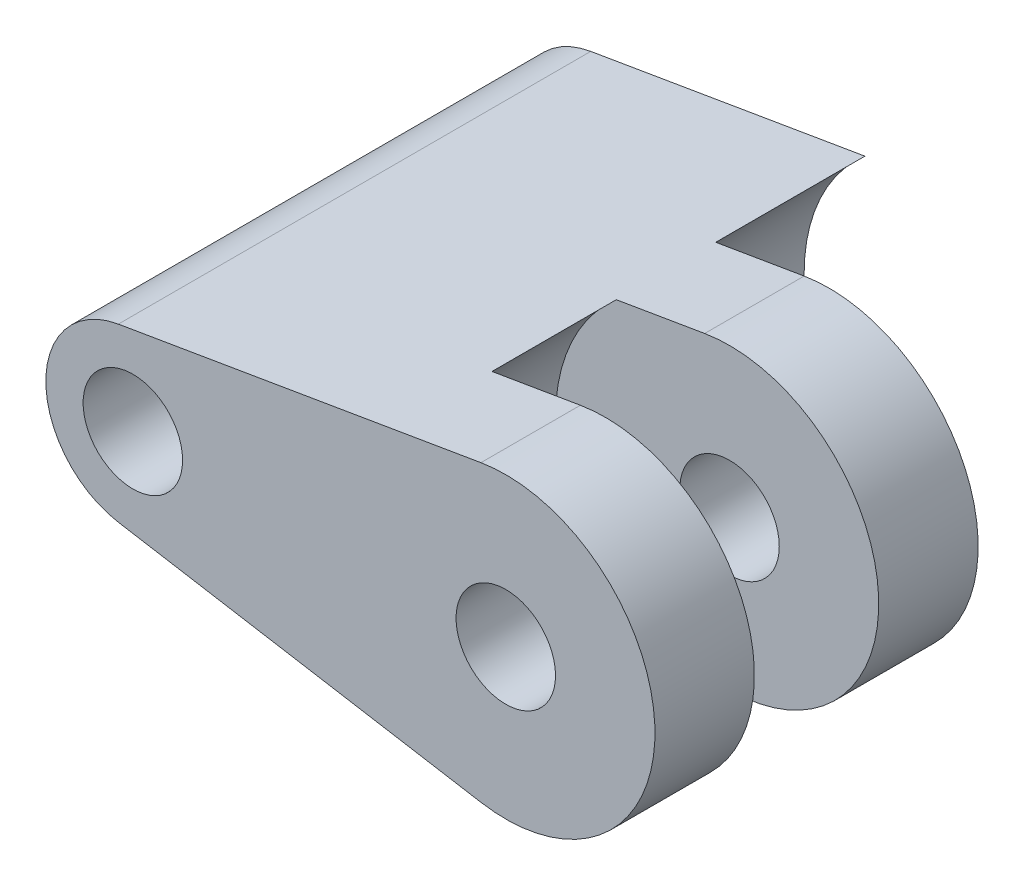
from build123d import *

# Parameters (mm, degrees)
ESQUISSE1_R        = 2
BOSS_EXTRU_2_DEPTH = 19
BOSS_EXTRU_3_START = 6
ESQUISSE1_4_R      = 2
BOSS_EXTRU_3_DEPTH = 4
BOSS_EXTRU_4_START = 15
ESQUISSE1_5_R      = 2
BOSS_EXTRU_4_DEPTH = 4


with BuildPart() as part:
    # Esquisse1 → Boss.-Extru.2 (new body)
    with BuildSketch(Plane.XY):
        with BuildLine():
            Line((10.444878499, 5.315154571), (-0.583333333, 3.45104654))
            ThreePointArc((-0.583333333, 3.45104654), (-3.5, 0), (-0.583333333, -3.45104654))
            Line((-0.583333333, -3.45104654), (10.444878499, -5.315154571))
            ThreePointArc((10.444878499, -5.315154571), (8, 0), (10.444878499, 5.315154571))
        make_face()
        Circle(ESQUISSE1_R, mode=Mode.SUBTRACT)
    extrude(amount=BOSS_EXTRU_2_DEPTH)

    # Esquisse1_4 → Boss.-Extru.3 (add)
    with BuildSketch(Plane.XY.offset(BOSS_EXTRU_3_START)):
        with BuildLine():
            Line((14, 5.916079783), (10.444878499, 5.315154571))
            ThreePointArc((10.444878499, 5.315154571), (8, 0), (10.444878499, -5.315154571))
            Line((10.444878499, -5.315154571), (14, -5.916079783))
            ThreePointArc((14, -5.916079783), (21, 0), (14, 5.916079783))
        make_face()
        with Locations((15, 0)):
            Circle(ESQUISSE1_4_R, mode=Mode.SUBTRACT)
    extrude(amount=BOSS_EXTRU_3_DEPTH)

    # Esquisse1_5 → Boss.-Extru.4 (add)
    with BuildSketch(Plane.XY.offset(BOSS_EXTRU_4_START)):
        with BuildLine():
            Line((14, 5.916079783), (10.444878499, 5.315154571))
            ThreePointArc((10.444878499, 5.315154571), (8, 0), (10.444878499, -5.315154571))
            Line((10.444878499, -5.315154571), (14, -5.916079783))
            ThreePointArc((14, -5.916079783), (21, 0), (14, 5.916079783))
        make_face()
        with Locations((15, 0)):
            Circle(ESQUISSE1_5_R, mode=Mode.SUBTRACT)
    extrude(amount=BOSS_EXTRU_4_DEPTH)


solid = part.part
